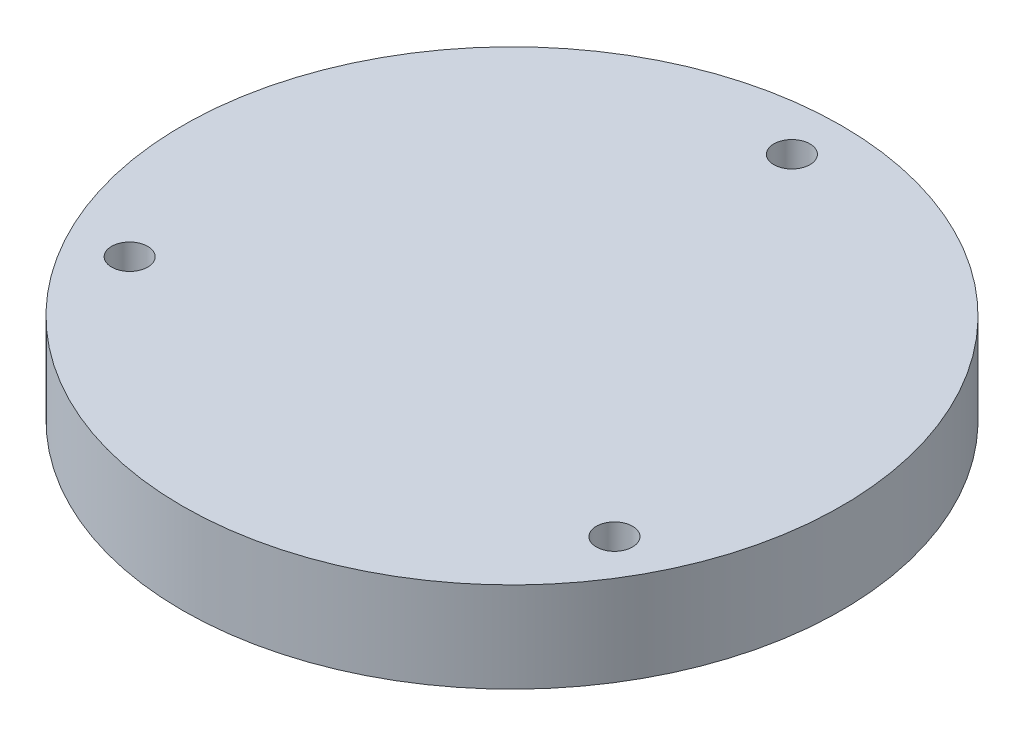
from build123d import *

# Parameters (mm, degrees)
SKETCH1_R           = 36.5
BOSS_EXTRUDE1_DEPTH = 10
SKETCH3_R           = 2
CUT_EXTRUDE1_DEPTH  = 11


with BuildPart() as part:
    # Sketch1 → Boss-Extrude1 (new body)
    with BuildSketch(Plane(origin=(0, 0, 0), x_dir=(1, 0, 0), z_dir=(0, 1, 0))):
        Circle(SKETCH1_R)
    extrude(amount=BOSS_EXTRUDE1_DEPTH)

    # Sketch3 → Cut-Extrude1 (cut, through all)
    with BuildSketch(Plane(origin=(0, 10, 0), x_dir=(1, 0, 0), z_dir=(0, 1, 0))):
        with Locations((0, 31)):
            Circle(SKETCH3_R)
        with Locations((26.846787517, -15.5)):
            Circle(SKETCH3_R)
        with Locations((-26.846787517, -15.5)):
            Circle(SKETCH3_R)
    extrude(amount=-CUT_EXTRUDE1_DEPTH, mode=Mode.SUBTRACT)


solid = part.part
